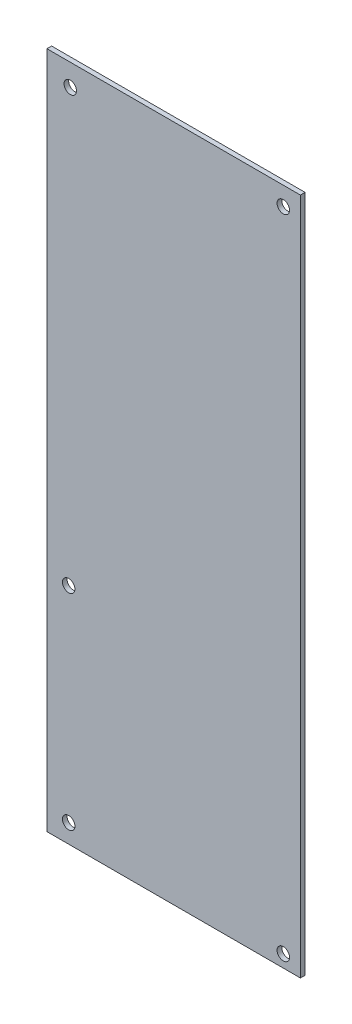
from build123d import *

# Parameters (mm, degrees)
MAIN_SKETCH_W = 81.5
MAIN_SKETCH_H = 218
MAIN_DEPTH    = 1.5
HOLE_SKETCH_R = 2
HOLE_DEPTH    = 2.5


with BuildPart() as part:
    # Main-Sketch → Main (new body)
    with BuildSketch(Plane.XY):
        with Locations((40.75, 109)):
            Rectangle(MAIN_SKETCH_W, MAIN_SKETCH_H)
    extrude(amount=MAIN_DEPTH)

    # Hole-Sketch → Hole (cut, through all)
    with BuildSketch(Plane.XY.offset(1.5)):
        with Locations((7.5, 211)):
            Circle(HOLE_SKETCH_R)
        with Locations((76, 212)):
            Circle(HOLE_SKETCH_R)
        with Locations((7, 6)):
            Circle(HOLE_SKETCH_R)
        with Locations((76, 4)):
            Circle(HOLE_SKETCH_R)
        with Locations((7, 72)):
            Circle(HOLE_SKETCH_R)
    extrude(amount=-HOLE_DEPTH, mode=Mode.SUBTRACT)


solid = part.part
